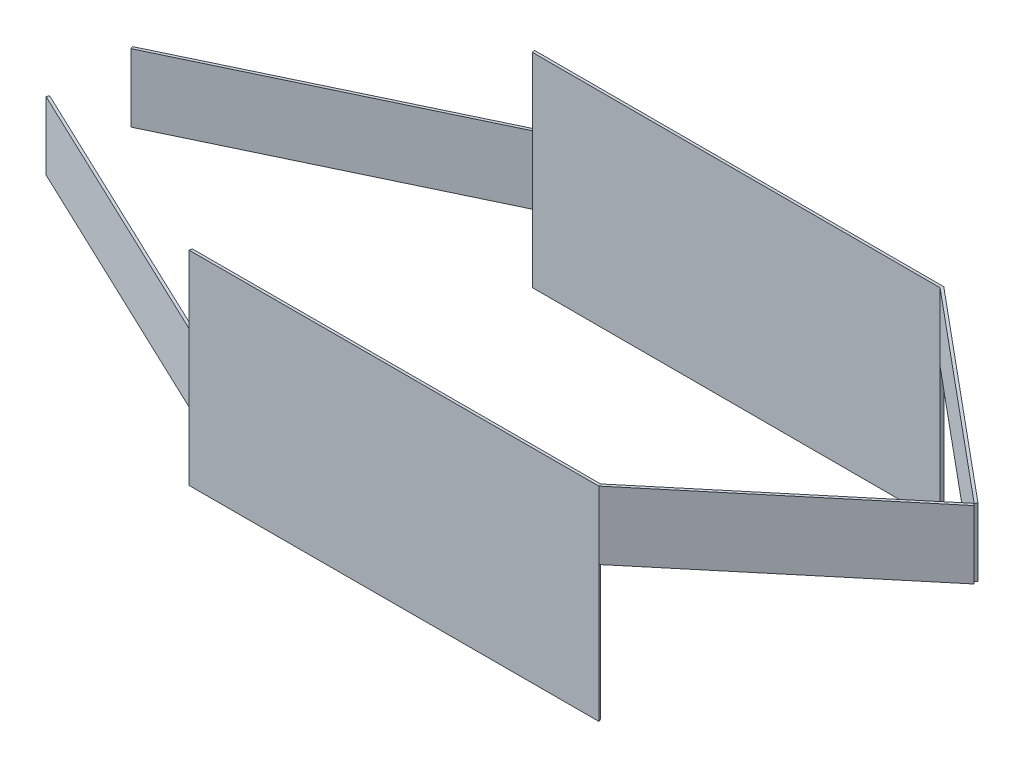
from build123d import *

# Parameters (mm, degrees)
BOSS_EXTRUDE2_DEPTH   = 300
BOSS_EXTRUDE2_2_DEPTH = 300
BOSS_EXTRUDE3_DEPTH   = 100
BOSS_EXTRUDE6_START   = -100
BOSS_EXTRUDE6_DEPTH   = 100


with BuildPart() as part:
    # Sketch1 → Boss-Extrude2 (new body)
    with BuildSketch(Plane(origin=(0, 0, 0), x_dir=(1, 0, 0), z_dir=(0, 1, 0))):
        Polygon((1001.466566722, 254.686940296), (399.095334701, 254.686940296), (400, 250.686940296), (1000, 250.686940296), align=None)
    extrude(amount=-BOSS_EXTRUDE2_DEPTH)

    # Sketch1_8 → Boss-Extrude3 (add)
    with BuildSketch(Plane(origin=(0, 0, 0), x_dir=(1, 0, 0), z_dir=(0, 1, 0))):
        Polygon((1302.571620685, -2.186929879), (1300, 0.892945716), (1000.343440579, -249.312941753), (1001.815500965, -253.310923265), align=None)
        Polygon((1302.567387242, 3.976351199), (1001.466566722, 254.686940296), (1000, 250.686940296), (1300, 0.892945716), align=None)
    extrude(amount=-BOSS_EXTRUDE3_DEPTH)


with BuildPart() as body_2:
    # Sketch1 → Boss-Extrude2 2 (new body)
    with BuildSketch(Plane(origin=(0, 0, 0), x_dir=(1, 0, 0), z_dir=(0, 1, 0))):
        Polygon((1001.815500965, -253.310923265), (1000.343440579, -249.312941753), (400.344006746, -250.137198948), (399.444837348, -254.138437968), align=None)
    extrude(amount=-BOSS_EXTRUDE2_2_DEPTH)


with BuildPart() as boss_extrude3_piece_1:
    # of the separate pieces the step leaves, piece 1, a body of its own (boss_extrude3_pieces)
    add(part.part.solids().sort_by_distance((1001.466566722, 0, -254.686940296))[0])

    # Sketch1_11 → Boss-Extrude6 (add)
    with BuildSketch(Plane(origin=(0, 0, 0), x_dir=(1, 0, 0), z_dir=(0, 1, 0)).offset(BOSS_EXTRUDE6_START)):
        Polygon((399.095334701, 254.686940296), (-1.721284804, 63.610717496), (0, 60.000014154), (400, 250.686940296), align=None)
        Polygon((399.444837348, -254.138437968), (400.344006746, -250.137198948), (0.082425739, -59.999957537), (-1.633897194, -63.613022108), align=None)
    extrude(amount=-BOSS_EXTRUDE6_DEPTH)


with BuildPart() as boss_extrude3_piece_2:
    # of the separate pieces the step leaves, piece 2, a body of its own (boss_extrude3_pieces)
    add(part.part.solids().sort_by_distance((1000.343440579, 0, 249.312941753))[0])


with BuildPart() as boss_extrude6_piece_1:
    # of the separate pieces the step leaves, piece 1, a body of its own (boss_extrude6_pieces)
    add(boss_extrude3_piece_1.part.solids().sort_by_distance((1001.466566722, 0, -254.686940296))[0])


with BuildPart() as boss_extrude6_piece_2:
    # of the separate pieces the step leaves, piece 2, a body of its own (boss_extrude6_pieces)
    add(boss_extrude3_piece_1.part.solids().sort_by_distance((0.082425739, -100, 59.999957537))[0])


solid = Compound([body_2.part, boss_extrude3_piece_2.part, boss_extrude6_piece_1.part, boss_extrude6_piece_2.part])
